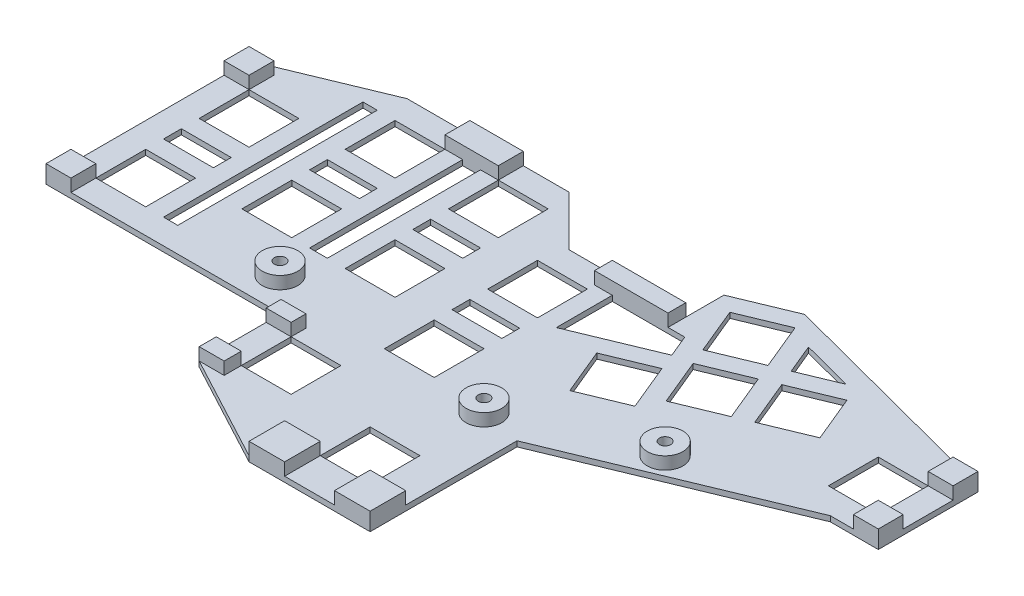
from build123d import *

# Parameters (mm, degrees)
SKETCH2_W            = 14
SKETCH2_H            = 14
SKETCH2_W_2          = 4
SKETCH2_H_2          = 56
SKETCH2_W_3          = 5
SKETCH2_H_3          = 43
SKETCH2_H_4          = 5
KEY_PLATE_DEPTH      = 1.5
SKETCH4_W            = 10
SKETCH4_H            = 10
SKETCH4_W_2          = 7
SKETCH4_H_2          = 7
SKETCH4_H_3          = 4.796695527
SKETCH4_H_4          = 4.186773245
SKETCH4_W_3          = 15
SKETCH4_W_4          = 20.633111118
SKETCH4_H_5          = 5
STANDOFFS_DEPTH      = 3.5
SKETCH6_R            = 5
SCREW_GUIDES_DEPTH   = 3.5
M3_CLEARANCE_HOLE1_D = 3.2


with BuildPart() as part:
    # Sketch2 → Key Plate (new body)
    with BuildSketch(Plane(origin=(0, 0, 0), x_dir=(1, 0, 0), z_dir=(0, 1, 0))):
        Polygon((-132.282827099, 11.085546756), (-132.282827099, 68.085546756), (-100.898050788, 81.085546756), (-55.483837226, 81.085546756), (-41.483837226, 67.085546756), (-8.649715981, 67.085546756), (-8.649715981, 77.800355514), (7.371180312, 84.43642804), (73.386249254, 67.093850916), (73.386249254, 39.093850916), (59.91832331, 39.093850916), (-2.282827099, 13.329290821), (-2.282827099, -27.914453244), (-36.282827099, -27.914453244), (-66.282827099, -11.897922016), (-66.282827099, 11.085546756), align=None)
        Polygon((5.863113655, 38.297174055), (-7.0711998, 32.939606002), (-12.428767853, 45.873919457), (0.505545602, 51.23148751), align=None, mode=Mode.SUBTRACT)
        with Locations((-118.282827099, 54.085546756)):
            Rectangle(SKETCH2_W, SKETCH2_H, mode=Mode.SUBTRACT)
        with Locations((-90.282827099, 67.085546756)):
            Rectangle(SKETCH2_W, SKETCH2_H, mode=Mode.SUBTRACT)
        with Locations((-61.282827099, 67.085546756)):
            Rectangle(SKETCH2_W, SKETCH2_H, mode=Mode.SUBTRACT)
        with Locations((-36.282827099, 53.085546756)):
            Rectangle(SKETCH2_W, SKETCH2_H, mode=Mode.SUBTRACT)
        with Locations((-61.282827099, 38.085546756)):
            Rectangle(SKETCH2_W, SKETCH2_H, mode=Mode.SUBTRACT)
        with Locations((-90.282827099, 38.085546756)):
            Rectangle(SKETCH2_W, SKETCH2_H, mode=Mode.SUBTRACT)
        with Locations((-118.282827099, 25.085546756)):
            Rectangle(SKETCH2_W, SKETCH2_H, mode=Mode.SUBTRACT)
        with Locations((-52.282827099, -0.101226489)):
            Rectangle(SKETCH2_W, SKETCH2_H, mode=Mode.SUBTRACT)
        with Locations((-36.282827099, 24.085546756)):
            Rectangle(SKETCH2_W, SKETCH2_H, mode=Mode.SUBTRACT)
        with Locations((-19.282827099, -10.914453244)):
            Rectangle(SKETCH2_W, SKETCH2_H, mode=Mode.SUBTRACT)
        with Locations((59.386249254, 53.093850916)):
            Rectangle(SKETCH2_W, SKETCH2_H, mode=Mode.SUBTRACT)
        Polygon((-3.649715981, 74.459462324), (9.284597474, 79.817030378), (14.642165527, 66.882716922), (1.707852072, 61.525148869), align=None, mode=Mode.SUBTRACT)
        Polygon((3.640403405, 56.85955723), (16.57471686, 62.217125283), (21.932284914, 49.282811828), (8.997971458, 43.925243775), align=None, mode=Mode.SUBTRACT)
        Polygon((26.597876553, 51.215363162), (39.532190008, 56.572931215), (34.174621955, 69.50724467), (21.2403085, 64.149676617), align=None, mode=Mode.SUBTRACT)
        Polygon((-24.282827099, 62.085546756), (-3.936233335, 62.085546756), (-1.361677583, 55.870019344), (-24.282827099, 46.37576835), align=None, mode=Mode.SUBTRACT)
        with Locations((-104.282827099, 46.085546756)):
            Rectangle(SKETCH2_W_2, SKETCH2_H_2, mode=Mode.SUBTRACT)
        with Locations((-75.782827099, 52.585546756)):
            Rectangle(SKETCH2_W_3, SKETCH2_H_3, mode=Mode.SUBTRACT)
        with Locations((-90.282827099, 52.585546756)):
            Rectangle(SKETCH2_W, SKETCH2_H_4, mode=Mode.SUBTRACT)
        with Locations((-61.282827099, 52.585546756)):
            Rectangle(SKETCH2_W, SKETCH2_H_4, mode=Mode.SUBTRACT)
        with Locations((-36.282827099, 38.585546756)):
            Rectangle(SKETCH2_W, SKETCH2_H_4, mode=Mode.SUBTRACT)
        with Locations((-118.282827099, 39.585546756)):
            Rectangle(SKETCH2_W, SKETCH2_H_4, mode=Mode.SUBTRACT)
        Polygon((19.280697361, 68.749940108), (30.195022846, 73.270801748), (15.846767853, 77.040179298), align=None, mode=Mode.SUBTRACT)
    extrude(amount=KEY_PLATE_DEPTH)

    # Sketch4 → Standoffs (add)
    with BuildSketch(Plane.XZ.offset(-1.5)):
        with Locations((-7.282827099, 22.914453244)):
            Rectangle(SKETCH4_W, SKETCH4_H)
        with Locations((69.886249254, -42.593850916)):
            Rectangle(SKETCH4_W_2, SKETCH4_H_2)
        with Locations((69.886249254, -63.593850916)):
            Rectangle(SKETCH4_W_2, SKETCH4_H_2)
        with Locations((-128.782827099, -14.585546756)):
            Rectangle(SKETCH4_W_2, SKETCH4_H_2)
        with Locations((-128.782827099, -64.585546756)):
            Rectangle(SKETCH4_W_2, SKETCH4_H_2)
        with Locations((-62.782827099, 9.499574253)):
            Rectangle(SKETCH4_W_2, SKETCH4_H_3)
        with Locations((-31.282827099, 22.914453244)):
            Rectangle(SKETCH4_W, SKETCH4_H)
        with Locations((-62.782827099, -8.992160134)):
            Rectangle(SKETCH4_W_2, SKETCH4_H_4)
        with Locations((-75.782827099, -77.585546756)):
            Rectangle(SKETCH4_W_3, SKETCH4_H_2)
        with Locations((-18.96627154, -64.585546756)):
            Rectangle(SKETCH4_W_4, SKETCH4_H_5)
    extrude(amount=-STANDOFFS_DEPTH)

    # Sketch6 → Screw Guides (add)
    with BuildSketch(Plane.XZ.offset(-1.5)):
        with Locations((22.140830524, -30.487456679)):
            Circle(SKETCH6_R)
        with Locations((-13.803783609, -15.564500098)):
            Circle(SKETCH6_R)
        with Locations((-75.782827099, -20.294986151)):
            Circle(SKETCH6_R)
    extrude(amount=-SCREW_GUIDES_DEPTH)

    # M3 Clearance Hole1 (through all)
    with Locations(Plane(origin=(22.140830524, 5, -30.487456679), x_dir=(0, 0, 1), z_dir=(0, 1, 0))):
        with Locations((0, 0), (10.192470528, -97.923657623), (14.922956581, -35.944614133)):
            Hole(M3_CLEARANCE_HOLE1_D / 2)


solid = part.part
